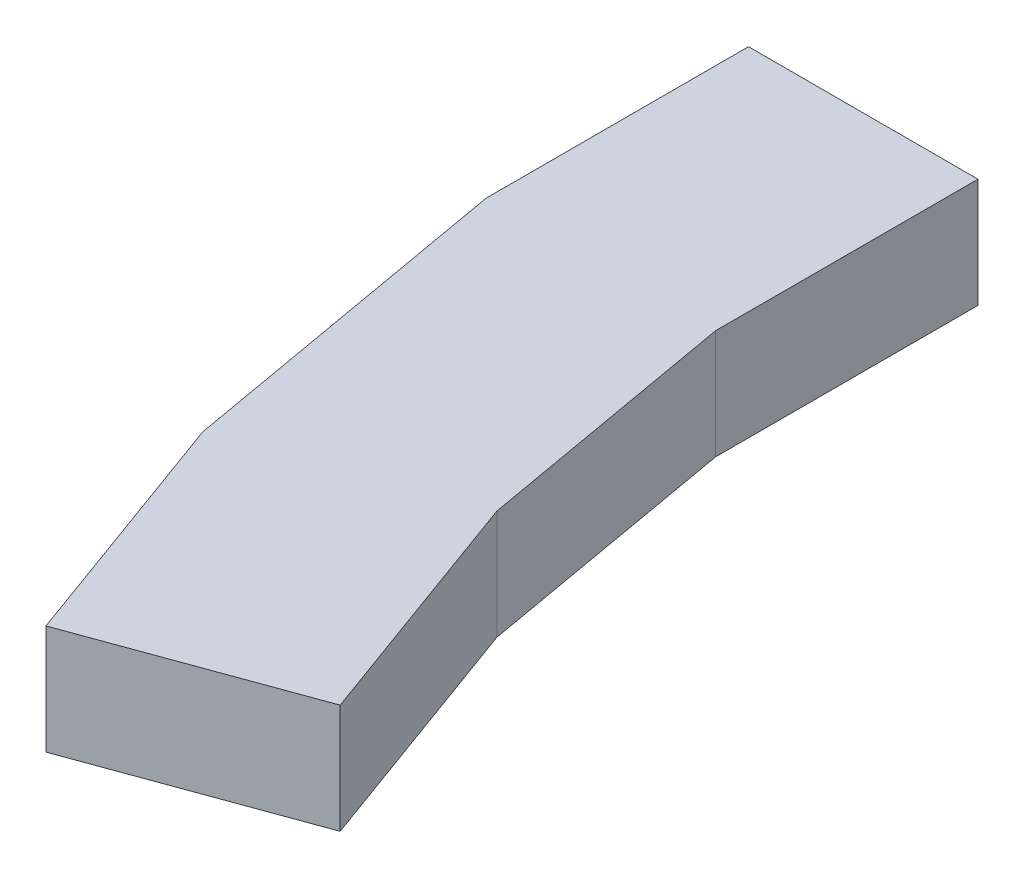
from build123d import *

# Parameters (mm, degrees)
BOSS_EXTRUDE1_DEPTH = 10


with BuildPart() as part:
    # Sketch1 → Boss-Extrude1 (new body)
    with BuildSketch(Plane(origin=(0, 76.042436513, 0), x_dir=(1, 0, 0), z_dir=(0, 1, 0))):
        Polygon((37.112238255, 12.500000075), (42.664692059, -18.989530241), (50.873175486, -41.542153104), (70.606720523, -34.359730095), (62.398237096, -11.807107231), (58.112238255, 12.500000075), (58.112238255, 36.500000037), (37.112238255, 36.500000037), align=None)
    extrude(amount=BOSS_EXTRUDE1_DEPTH)


solid = part.part
